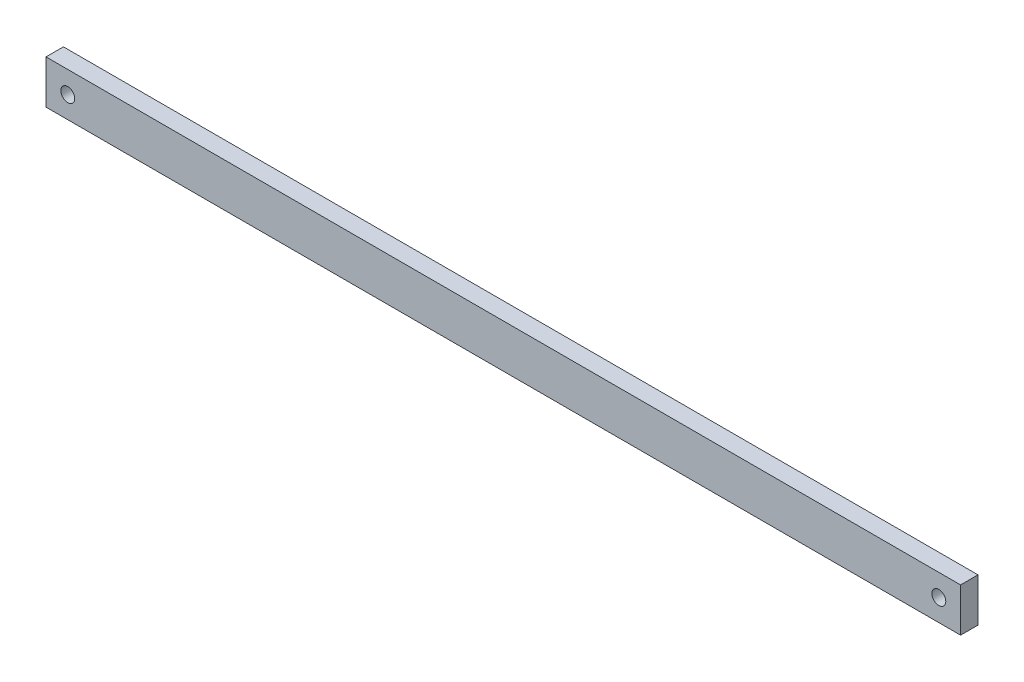
from build123d import *

# Parameters (mm, degrees)
SKETCH_1_W      = 210
SKETCH_1_H      = 10
SKETCH_1_R      = 1.6
EXTRUDE_1_DEPTH = 4


with BuildPart() as part:
    # 草图1 → 凸台-拉伸1 (new body)
    with BuildSketch(Plane.XY):
        Rectangle(SKETCH_1_W, SKETCH_1_H)
        with Locations((-100, 0)):
            Circle(SKETCH_1_R, mode=Mode.SUBTRACT)
        with Locations((100, 0)):
            Circle(SKETCH_1_R, mode=Mode.SUBTRACT)
    extrude(amount=EXTRUDE_1_DEPTH)


solid = part.part
